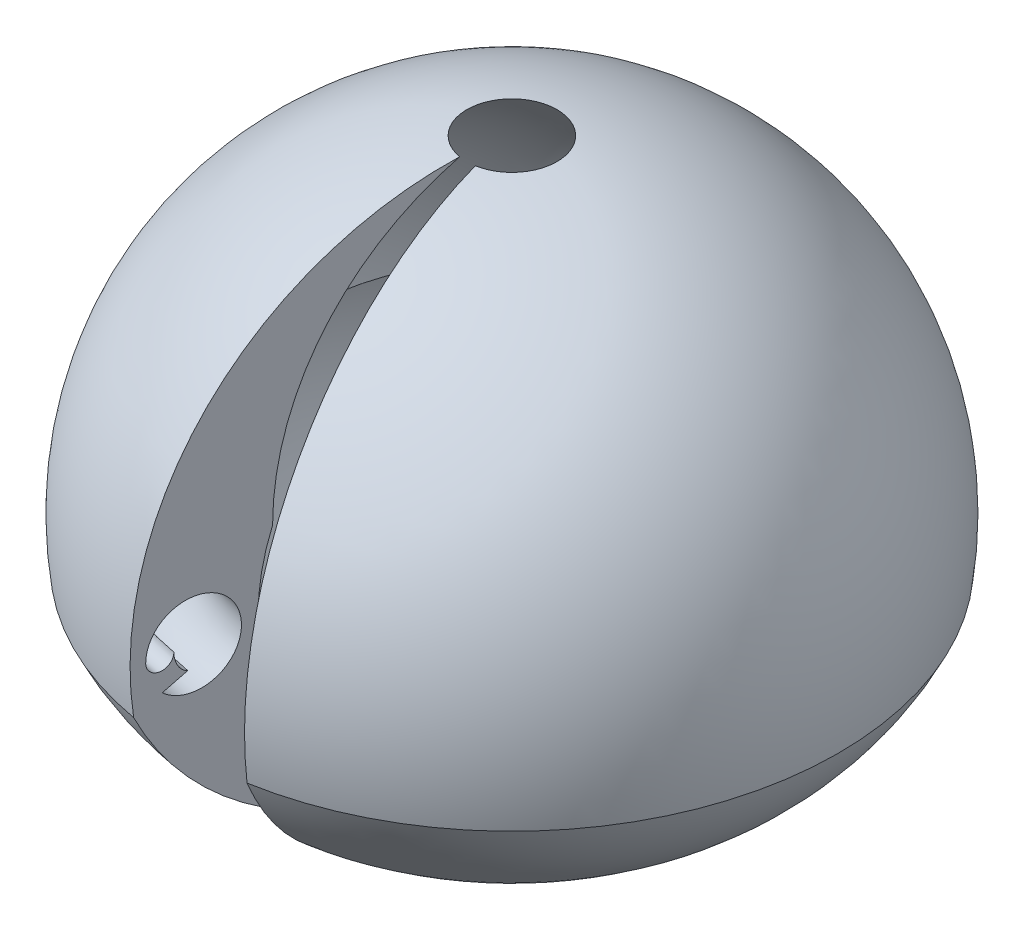
from build123d import *

# Parameters (mm, degrees)
REVOLVE1_ANGLE           = 170
REVOLVE1_OTHER_WAY_ANGLE = 170


with BuildPart() as part:
    # Sketch1 → Revolve1 (revolve)
    with BuildSketch(Plane(origin=(0, 0, 0), x_dir=(0, 0, -1), z_dir=(1, 0, 0))):
        with BuildLine():
            ThreePointArc((2.685548674, -0.370981238), (2.161293028, 1.63664633), (0.370981238, 2.685548674))
            ThreePointArc((0.370981238, 2.685548674), (1.338759561, 1.836829863), (1.698959236, 0.601040764))
            ThreePointArc((1.698959236, 0.601040764), (1.626345597, -0.776345597), (0.601040764, -1.698959236))
            ThreePointArc((0.601040764, -1.698959236), (1.836829863, -1.338759561), (2.685548674, -0.370981238))
        make_face()
        with BuildLine():
            Line((2.301515604, -0.191903676), (2.483091519, -0.276573916))
            ThreePointArc((2.483091519, -0.276573916), (1.950604528, 0.120976742), (2.6, -0.02))
            ThreePointArc((2.6, -0.02), (2.5, -0.12), (2.4, -0.02))
            add(Edge.make_bspline(
                [(2.301515604, -0.191903676), (2.4, -0.152586478), (2.4, -0.02)],
                knots=[3.442660331, 3.442660331, 3.442660331, 4.71238898, 4.71238898, 4.71238898], degree=2, weights=[1, 0.805152169, 1]))
        make_face(mode=Mode.SUBTRACT)
    revolve(axis=Axis((0, 0, 0), (0, 1, 0)), revolution_arc=REVOLVE1_ANGLE)

    # Sketch1 → Revolve1 other way (revolve)
    with BuildSketch(Plane(origin=(0, 0, 0), x_dir=(0, 0, -1), z_dir=(1, 0, 0))):
        with BuildLine():
            ThreePointArc((2.685548674, -0.370981238), (2.161293028, 1.63664633), (0.370981238, 2.685548674))
            ThreePointArc((0.370981238, 2.685548674), (1.338759561, 1.836829863), (1.698959236, 0.601040764))
            ThreePointArc((1.698959236, 0.601040764), (1.626345597, -0.776345597), (0.601040764, -1.698959236))
            ThreePointArc((0.601040764, -1.698959236), (1.836829863, -1.338759561), (2.685548674, -0.370981238))
        make_face()
        with BuildLine():
            Line((2.301515604, -0.191903676), (2.483091519, -0.276573916))
            ThreePointArc((2.483091519, -0.276573916), (1.950604528, 0.120976742), (2.6, -0.02))
            ThreePointArc((2.6, -0.02), (2.5, -0.12), (2.4, -0.02))
            add(Edge.make_bspline(
                [(2.301515604, -0.191903676), (2.4, -0.152586478), (2.4, -0.02)],
                knots=[3.442660331, 3.442660331, 3.442660331, 4.71238898, 4.71238898, 4.71238898], degree=2, weights=[1, 0.805152169, 1]))
        make_face(mode=Mode.SUBTRACT)
    revolve(axis=Axis((0, 0, 0), (0, -1, 0)), revolution_arc=REVOLVE1_OTHER_WAY_ANGLE)


solid = part.part
